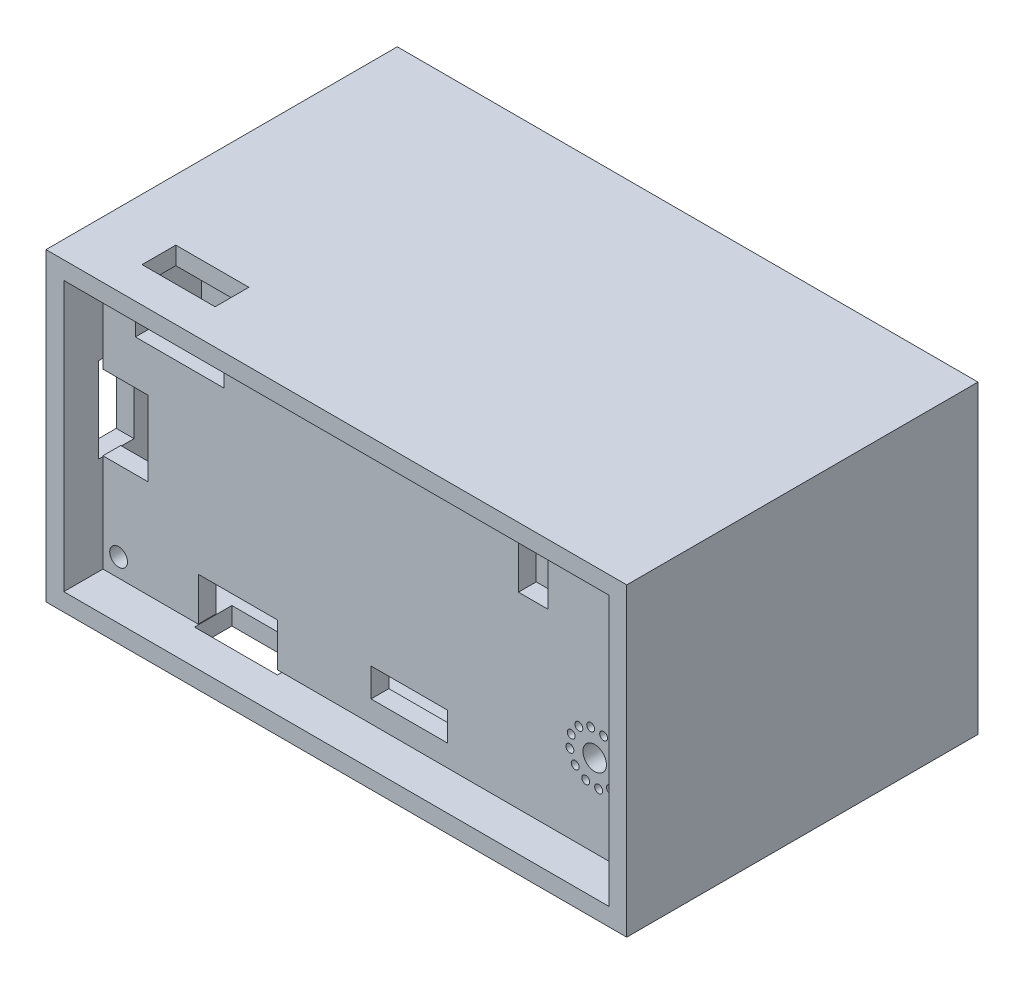
from build123d import *

# Parameters (mm, degrees)
SKETCH_1_R           = 1.00000254
SKETCH_1_R_2         = 1.321998217
SKETCH_1_R_3         = 0.44618067
SKETCH_1_W           = 8.619765629
SKETCH_1_H           = 3.207492673
SKETCH_1_W_2         = 3.29999996
SKETCH_1_H_2         = 5.499999934
EXTRUDE_1_DEPTH      = 2
SKETCH_2_W           = 65.2997206
SKETCH_2_H           = 34.311658624
SKETCH_2_R           = 1.00000254
SKETCH_2_R_2         = 0.922218434
SKETCH_2_R_3         = 1.5
EXTRUDE_2_DEPTH      = 4.5
SKETCH_3_R           = 1.5
CUT_EXTRUDE_2_DEPTH  = 2.5
SKETCH_5_W           = 65.2997206
SKETCH_5_H           = 34.311658624
SKETCH_5_W_2         = 61.2997206
SKETCH_5_H_2         = 30.311658624
EXTRUDE_3_DEPTH      = 15.5
EXTRUDE_3_DEPTH_BACK = 20
SKETCH_7_W           = 8.214112973
SKETCH_7_H           = 3.795011114
CUT_EXTRUDE_4_DEPTH  = 3
SKETCH_8_W           = 4
SKETCH_8_H           = 9.575559499
CUT_EXTRUDE_5_DEPTH  = 3
SKETCH_9_W           = 9.326303795
SKETCH_9_H           = 4.202278939
CUT_EXTRUDE_6_DEPTH  = 3
SKETCH_10_W          = 65.2997206
SKETCH_10_H          = 34.311658624
SKETCH_10_R          = 1
EXTRUDE_4_DEPTH      = 4


with BuildPart() as part:
    # 草图1 → 凸台-拉伸1 (new body)
    with BuildSketch(Plane.XY.offset(3.6000508)):
        Polygon((-48.703358121, -33.861776064), (-39.800977226, -33.861776064), (-39.800977226, -38.722377445), (0.876301753, -38.722377445), (0.876301753, -9.410718821), (-45.806551639, -9.410718821), (-45.806551639, -14.290668856), (-55.768739785, -14.290668856), (-55.768739785, -9.410718821), (-59.423418847, -9.410718821), (-59.423418847, -19.252115931), (-54.355663452, -19.252115931), (-54.355663452, -27.686571242), (-59.423418847, -27.686571242), (-59.423418847, -38.722377445), (-48.703358121, -38.722377445), align=None)
        with Locations((-57.658115316, -36.64983236)):
            Circle(SKETCH_1_R, mode=Mode.SUBTRACT)
        with Locations((-57.658115316, -11.24978156)):
            Circle(SKETCH_1_R, mode=Mode.SUBTRACT)
        with Locations((-1.016002032, -11.24978156)):
            Circle(SKETCH_1_R, mode=Mode.SUBTRACT)
        with Locations((-0.889001778, -36.83007366)):
            Circle(SKETCH_1_R, mode=Mode.SUBTRACT)
        with Locations((-4.125883596, -29.468931921)):
            Circle(SKETCH_1_R_2, mode=Mode.SUBTRACT)
        with Locations((-5.908244275, -27.277517049)):
            Circle(SKETCH_1_R_3, mode=Mode.SUBTRACT)
        with Locations((-4.573745786, -26.679930632)):
            Circle(SKETCH_1_R_3, mode=Mode.SUBTRACT)
        with Locations((-3.119242986, -26.829654858)):
            Circle(SKETCH_1_R_3, mode=Mode.SUBTRACT)
        with Locations((-1.934468724, -27.686571242)):
            Circle(SKETCH_1_R_3, mode=Mode.SUBTRACT)
        with Locations((-1.336882307, -29.021069731)):
            Circle(SKETCH_1_R_3, mode=Mode.SUBTRACT)
        with Locations((-1.486606533, -30.475572531)):
            Circle(SKETCH_1_R_3, mode=Mode.SUBTRACT)
        with Locations((-2.343522917, -31.660346793)):
            Circle(SKETCH_1_R_3, mode=Mode.SUBTRACT)
        with Locations((-3.678021405, -32.25793321)):
            Circle(SKETCH_1_R_3, mode=Mode.SUBTRACT)
        with Locations((-5.132524206, -32.108208984)):
            Circle(SKETCH_1_R_3, mode=Mode.SUBTRACT)
        with Locations((-6.317298468, -31.2512926)):
            Circle(SKETCH_1_R_3, mode=Mode.SUBTRACT)
        with Locations((-6.914884885, -29.916794112)):
            Circle(SKETCH_1_R_3, mode=Mode.SUBTRACT)
        with Locations((-6.765160658, -28.462291311)):
            Circle(SKETCH_1_R_3, mode=Mode.SUBTRACT)
        with Locations((-24.963675733, -34.688330417)):
            Rectangle(SKETCH_1_W, SKETCH_1_H, mode=Mode.SUBTRACT)
        with Locations((-11.049022098, -14.859029718)):
            Rectangle(SKETCH_1_W_2, SKETCH_1_H_2, mode=Mode.SUBTRACT)
    extrude(amount=EXTRUDE_1_DEPTH)


with BuildPart() as body_2:
    # 草图2 → 凸台-拉伸2 (new body)
    with BuildSketch(Plane(origin=(0, 0, -6), x_dir=(-1, 0, 0), z_dir=(0, 0, -1))):
        with Locations((29.273558547, -24.066548133)):
            Rectangle(SKETCH_2_W, SKETCH_2_H)
        with Locations((1.016002032, -11.24978156)):
            Circle(SKETCH_2_R, mode=Mode.SUBTRACT)
        with Locations((0.889001778, -36.83007366)):
            Circle(SKETCH_2_R, mode=Mode.SUBTRACT)
        with Locations((57.658115316, -36.64983236)):
            Circle(SKETCH_2_R, mode=Mode.SUBTRACT)
        with Locations((57.658115316, -11.24978156)):
            Circle(SKETCH_2_R_2, mode=Mode.SUBTRACT)
        with Locations((29.273558547, -32.316548133)):
            Circle(SKETCH_2_R_3, mode=Mode.SUBTRACT)
        with BuildLine():
            Line((27.785407033, -15.816548133), (27.785407033, -13.183619987))
            ThreePointArc((27.785407033, -13.183619987), (29.273558547, -11.695468472), (30.761710061, -13.183619987))
            Line((30.761710061, -13.183619987), (30.761710061, -15.816548133))
            ThreePointArc((30.761710061, -15.816548133), (29.273558547, -17.304699647), (27.785407033, -15.816548133))
        make_face(mode=Mode.SUBTRACT)
    extrude(amount=EXTRUDE_2_DEPTH)

    # 草图3 → 切除-拉伸2 (cut)
    with BuildSketch(Plane(origin=(0, 0, -6), x_dir=(-1, 0, 0), z_dir=(0, 0, -1))):
        Polygon((29.273558547, -18.991974614), (32.023558547, -17.404261373), (32.023558547, -14.920341582), (32.023558547, -14.228834893), (32.023558547, -11.744915102), (29.273558547, -10.157201862), (26.523558547, -11.744915102), (26.523558547, -14.228834893), (26.523558547, -14.920341582), (26.523558547, -17.404261373), align=None)
        with BuildLine():
            ThreePointArc((30.761710061, -15.816548133), (29.273558547, -17.304699647), (27.785407033, -15.816548133))
            Line((27.785407033, -15.816548133), (27.785407033, -13.183619987))
            ThreePointArc((27.785407033, -13.183619987), (29.273558547, -11.695468472), (30.761710061, -13.183619987))
            Line((30.761710061, -13.183619987), (30.761710061, -15.816548133))
        make_face(mode=Mode.SUBTRACT)
        Polygon((26.523558547, -30.728834893), (26.523558547, -33.904261373), (29.273558547, -35.491974614), (32.023558547, -33.904261373), (32.023558547, -30.728834893), (29.273558547, -29.141121653), align=None)
        with Locations((29.273558547, -32.316548133)):
            Circle(SKETCH_3_R, mode=Mode.SUBTRACT)
    extrude(amount=CUT_EXTRUDE_2_DEPTH, mode=Mode.SUBTRACT)

    # 草图5 → 凸台-拉伸3 (add, two sides)
    with BuildSketch(Plane(origin=(0, 0, -10.5), x_dir=(-1, 0, 0), z_dir=(0, 0, -1))) as extrude_3_sk:
        with Locations((29.273558547, -24.066548133)):
            Rectangle(SKETCH_5_W, SKETCH_5_H)
        with Locations((29.273558547, -24.066548133)):
            Rectangle(SKETCH_5_W_2, SKETCH_5_H_2, mode=Mode.SUBTRACT)
    extrude(amount=EXTRUDE_3_DEPTH)
    extrude(extrude_3_sk.sketch, amount=-EXTRUDE_3_DEPTH_BACK)

    # 草图7 → 切除-拉伸4 (cut)
    with BuildSketch(Plane(origin=(0, -6.910718821, 0), x_dir=(1, 0, 0), z_dir=(0, 1, 0))):
        with Locations((-50.955145133, -3.662545243)):
            Rectangle(SKETCH_7_W, SKETCH_7_H)
    extrude(amount=-CUT_EXTRUDE_4_DEPTH, mode=Mode.SUBTRACT)

    # 草图8 → 切除-拉伸5 (cut)
    with BuildSketch(Plane.ZY.offset(61.923418847)):
        with Locations((3.6000508, -23.483057223)):
            Rectangle(SKETCH_8_W, SKETCH_8_H)
    extrude(amount=-CUT_EXTRUDE_5_DEPTH, mode=Mode.SUBTRACT)

    # 草图9 → 切除-拉伸6 (cut)
    with BuildSketch(Plane.XZ.offset(41.222377445)):
        with Locations((-44.464129124, 3.49891133)):
            Rectangle(SKETCH_9_W, SKETCH_9_H)
    extrude(amount=-CUT_EXTRUDE_6_DEPTH, mode=Mode.SUBTRACT)

    # 草图10 → 凸台-拉伸4 (add)
    with BuildSketch(Plane(origin=(0, 0, -26), x_dir=(-1, 0, 0), z_dir=(0, 0, -1))):
        with Locations((29.273558547, -24.066548133)):
            Rectangle(SKETCH_10_W, SKETCH_10_H)
        Polygon((-1.376301753, -14.910718821), (-1.376301753, -8.910718821), (4.623698247, -8.910718821), (53.923418847, -8.910718821), (59.923418847, -8.910718821), (59.923418847, -14.910718821), (59.923418847, -33.222377445), (59.923418847, -39.222377445), (53.923418847, -39.222377445), (4.623698247, -39.222377445), (-1.376301753, -39.222377445), (-1.376301753, -33.222377445), align=None, mode=Mode.SUBTRACT)
        with BuildLine():
            Line((4.623698247, -8.910718821), (-1.376301753, -8.910718821))
            Line((-1.376301753, -8.910718821), (-1.376301753, -14.910718821))
            ThreePointArc((-1.376301753, -14.910718821), (2.866338935, -13.153359509), (4.623698247, -8.910718821))
        make_face()
        with Locations((1.016002032, -11.24978156)):
            Circle(SKETCH_10_R, mode=Mode.SUBTRACT)
        with BuildLine():
            ThreePointArc((4.623698247, -39.222377445), (2.866338935, -34.979736758), (-1.376301753, -33.222377445))
            Line((-1.376301753, -33.222377445), (-1.376301753, -39.222377445))
            Line((-1.376301753, -39.222377445), (4.623698247, -39.222377445))
        make_face()
        with Locations((1.016002032, -36.883314707)):
            Circle(SKETCH_10_R, mode=Mode.SUBTRACT)
        with BuildLine():
            Line((59.923418847, -39.222377445), (59.923418847, -33.222377445))
            ThreePointArc((59.923418847, -33.222377445), (55.68077816, -34.979736758), (53.923418847, -39.222377445))
            Line((53.923418847, -39.222377445), (59.923418847, -39.222377445))
        make_face()
        with Locations((57.658115316, -36.883314707)):
            Circle(SKETCH_10_R, mode=Mode.SUBTRACT)
        with BuildLine():
            Line((59.923418847, -8.910718821), (53.923418847, -8.910718821))
            ThreePointArc((53.923418847, -8.910718821), (55.68077816, -13.153359509), (59.923418847, -14.910718821))
            Line((59.923418847, -14.910718821), (59.923418847, -8.910718821))
        make_face()
        with Locations((57.658115316, -11.24978156)):
            Circle(SKETCH_10_R, mode=Mode.SUBTRACT)
    extrude(amount=EXTRUDE_4_DEPTH)


solid = Compound([part.part, body_2.part])
